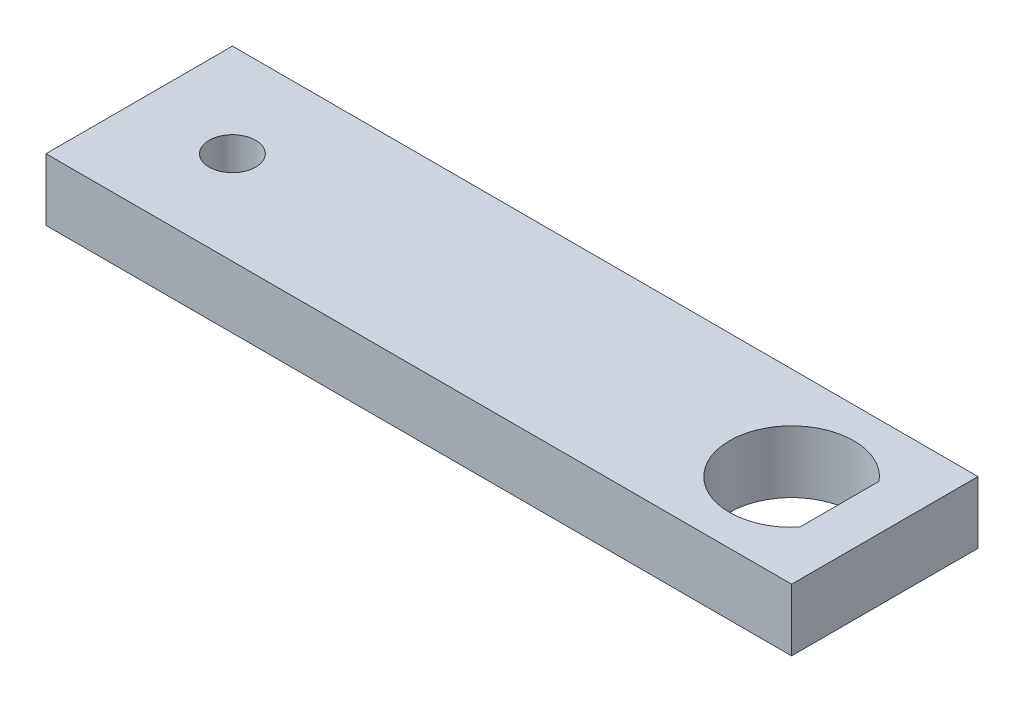
from build123d import *

# Parameters (mm, degrees)
SKETCH1_W          = 76.2
SKETCH1_H          = 6.35
BASE_EXTRUDE_DEPTH = 19.05
CUT_EXTRUDE1_DEPTH = 7.35
SKETCH3_R          = 2.38125
CUT_EXTRUDE2_DEPTH = 7.35


with BuildPart() as part:
    # Sketch1 → Base-Extrude (new body)
    with BuildSketch(Plane.XY):
        with Locations((38.1, 3.175)):
            Rectangle(SKETCH1_W, SKETCH1_H)
    extrude(amount=BASE_EXTRUDE_DEPTH)

    # Sketch2 → Cut-Extrude1 (cut, through all)
    with BuildSketch(Plane(origin=(0, 6.35, 0), x_dir=(-1, 0, 0), z_dir=(0, 1, 0))):
        with BuildLine():
            Line((-71.5645, 5.473421326), (-71.5645, 13.576578674))
            ThreePointArc((-71.5645, 13.576578674), (-60.325, 9.525), (-71.5645, 5.473421326))
        make_face()
    extrude(amount=-CUT_EXTRUDE1_DEPTH, mode=Mode.SUBTRACT)

    # Sketch3 → Cut-Extrude2 (cut, through all)
    with BuildSketch(Plane(origin=(0, 6.35, 0), x_dir=(-1, 0, 0), z_dir=(0, 1, 0))):
        with Locations((-9.525, 9.525)):
            Circle(SKETCH3_R)
    extrude(amount=-CUT_EXTRUDE2_DEPTH, mode=Mode.SUBTRACT)


solid = part.part
